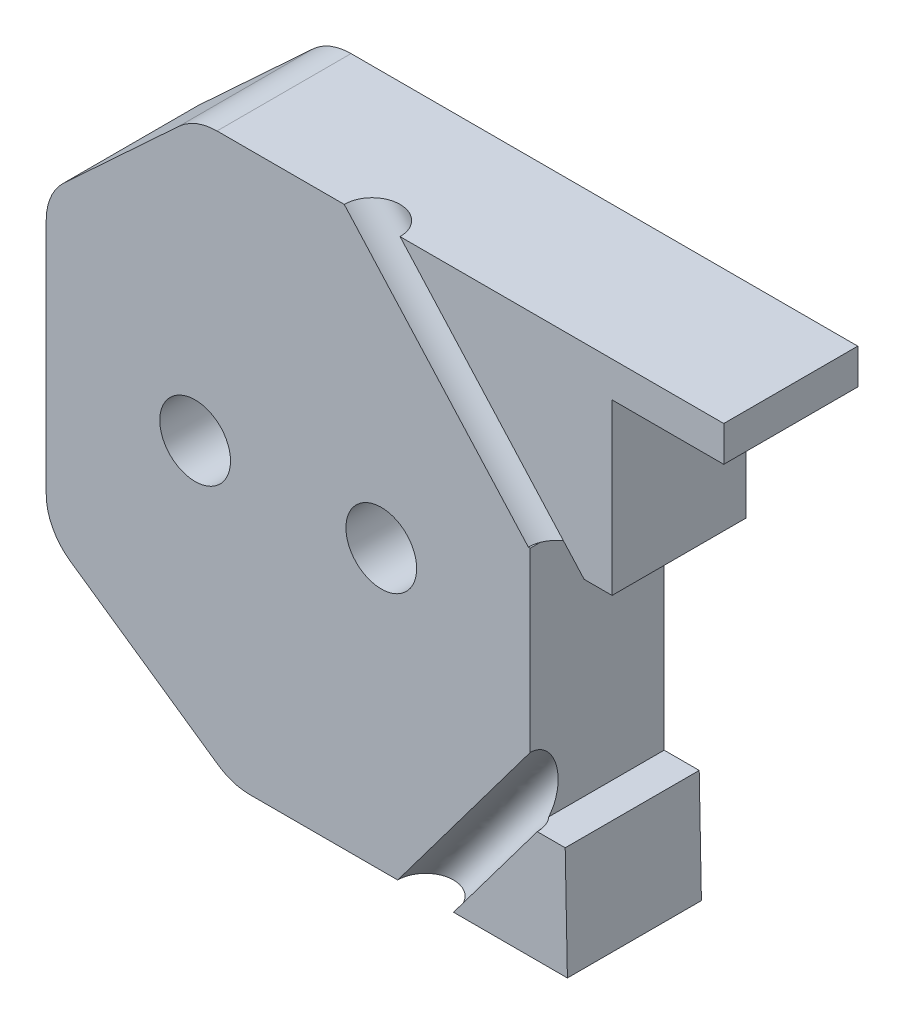
from build123d import *

# Parameters (mm, degrees)
BOSS_EXTRUDE1_DEPTH      = 2
BOSS_EXTRUDE2_DEPTH      = 6
SKETCH24_R               = 3.9
BOSS_EXTRUDE5_DEPTH      = 2.3
SKETCH30_W               = 2.408612022
SKETCH30_H               = 1.324178481
CUT_EXTRUDE12_DEPTH      = 8
CUT_EXTRUDE11_DEPTH      = 5.3
FILLET1_R                = 1.5
SKETCH34_R               = 0.75
CUT_EXTRUDE13_DEPTH      = 8
SKETCH35_R               = 0.75
CUT_EXTRUDE14_DEPTH      = 3
CUT_EXTRUDE14_DEPTH_BACK = 8
SKETCH36_R               = 0.95
CUT_EXTRUDE15_DEPTH      = 8
SKETCH37_R               = 2
CUT_EXTRUDE16_DEPTH      = 2.5
SKETCH38_W               = 3
SKETCH38_H               = 1.25
CUT_EXTRUDE17_DEPTH      = 3.6


with BuildPart() as part:
    # Sketch2 → Boss-Extrude1 (new body)
    with BuildSketch(Plane.XY):
        with BuildLine():
            Line((-2.5, 7.5), (-16.7, 7.5))
            Line((-16.7, 7.5), (-20.7, 3.793442666))
            Line((-20.7, 3.793442666), (-20.7, -4.031648778))
            Line((-20.7, -4.031648778), (-15.7, -7.5))
            Line((-15.7, -7.5), (-6.7, -7.5))
            Line((-6.7, -7.5), (-4.2, -5.6))
            ThreePointArc((-4.2, -5.6), (3.130495168, -6.260990337), (7, 0))
            ThreePointArc((7, 0), (4.949747468, 4.949747468), (0, 7))
            Line((0, 7), (0, 7.5))
            Line((0, 7.5), (-2.5, 7.5))
        make_face()
    extrude(amount=BOSS_EXTRUDE1_DEPTH)

    # Sketch4 → Boss-Extrude2 (add)
    with BuildSketch(Plane.XY.offset(2)):
        Polygon((-15.7, -7.5), (-6.7, -7.5), (-6.759079174, -4.5), (-7.7, -4.5), (-7.7, 2), (-5.5, 2), (-5.5, 5.3), (-2.5, 5.3), (-2.5, 7.5), (-16.7, 7.5), (-20.7, 3.793442666), (-20.7, -4.031648778), align=None)
    extrude(amount=BOSS_EXTRUDE2_DEPTH)

    # Sketch24 → Boss-Extrude5 (add)
    with BuildSketch(Plane.XY.offset(2)):
        Circle(SKETCH24_R)
    extrude(amount=BOSS_EXTRUDE5_DEPTH)

    # Sketch30 → Cut-Extrude12 (cut)
    with BuildSketch(Plane(origin=(-5.5, 0, 0), x_dir=(0, 0, -1), z_dir=(1, 0, 0))):
        with Locations((-3.261593395, 4.63791076)):
            Rectangle(SKETCH30_W, SKETCH30_H)
    extrude(amount=-CUT_EXTRUDE12_DEPTH, mode=Mode.SUBTRACT)

    # Sketch28 → Cut-Extrude11 (cut, through all)
    with BuildSketch(Plane.XY.offset(4.3)):
        with BuildLine():
            Line((-1, 1.732050808), (-1, -1.732050808))
            ThreePointArc((-1, -1.732050808), (2, 0), (-1, 1.732050808))
        make_face()
    extrude(amount=-CUT_EXTRUDE11_DEPTH, mode=Mode.SUBTRACT)

    # Fillet1
    fillet1_edges = [part.edges().sort_by_distance(p)[0] for p in [
        (-11.2, -7.5, 0),
        (-8.35, 7.5, 0),
        (-18.7, 5.646721333, 0),
        (-18.2, -5.765824389, 0),
        (-20.7, -0.119103056, 0),
        (-15.7, -7.5, 4),
        (-20.7, -4.031648778, 4),
        (-20.7, 3.793442666, 4),
        (-16.7, 7.5, 4),
    ]]
    fillet(fillet1_edges, radius=FILLET1_R)

    # Sketch34 → Cut-Extrude13 (cut, along a direction that is not the sketch's normal)
    with BuildSketch(Plane.XZ.offset(-2)):
        with Locations((-7, 8)):
            Circle(SKETCH34_R)
    extrude(amount=-CUT_EXTRUDE13_DEPTH, dir=(0.668583388, -0.743637179, 0), mode=Mode.SUBTRACT)

    # Sketch35 → Cut-Extrude14 (cut, two sides, along a direction that is not the sketch's normal)
    with BuildSketch(Plane(origin=(0, -4.5, 0), x_dir=(1, 0, 0), z_dir=(0, 1, 0))) as cut_extrude14_sk:
        with Locations((-8.259079174, -8)):
            Circle(SKETCH35_R)
    extrude(amount=CUT_EXTRUDE14_DEPTH, dir=(0.599919418, 0.80006043, 0), mode=Mode.SUBTRACT)
    extrude(cut_extrude14_sk.sketch, amount=-CUT_EXTRUDE14_DEPTH_BACK, dir=(0.599919418, 0.80006043, 0), mode=Mode.SUBTRACT)

    # Sketch36 → Cut-Extrude15 (cut)
    with BuildSketch(Plane.XY.offset(8)):
        with Locations((-11.7, 0)):
            Circle(SKETCH36_R)
        with Locations((-16.7, 0)):
            Circle(SKETCH36_R)
    extrude(amount=-CUT_EXTRUDE15_DEPTH, mode=Mode.SUBTRACT)

    # Sketch37 → Cut-Extrude16 (cut)
    with BuildSketch(Plane(origin=(0, 0, 0), x_dir=(-1, 0, 0), z_dir=(0, 0, -1))):
        with Locations((11.7, 0)):
            Circle(SKETCH37_R)
        with Locations((16.7, 0)):
            Circle(SKETCH37_R)
    extrude(amount=-CUT_EXTRUDE16_DEPTH, mode=Mode.SUBTRACT)

    # Sketch38 → Cut-Extrude17 (cut)
    with BuildSketch(Plane.XY.offset(8)):
        with Locations((-4, 5.925)):
            Rectangle(SKETCH38_W, SKETCH38_H)
    extrude(amount=-CUT_EXTRUDE17_DEPTH, mode=Mode.SUBTRACT)


with BuildPart() as body_2:
    # Split1: the piece on the far side of the plane
    add(part.part)
    split(bisect_by=Plane.XY.offset(4.4), keep=Keep.BOTTOM)


with BuildPart() as part_1:
    add(part.part)

    # Split1
    split(bisect_by=Plane.XY.offset(4.4), keep=Keep.TOP)


solid = part_1.part
